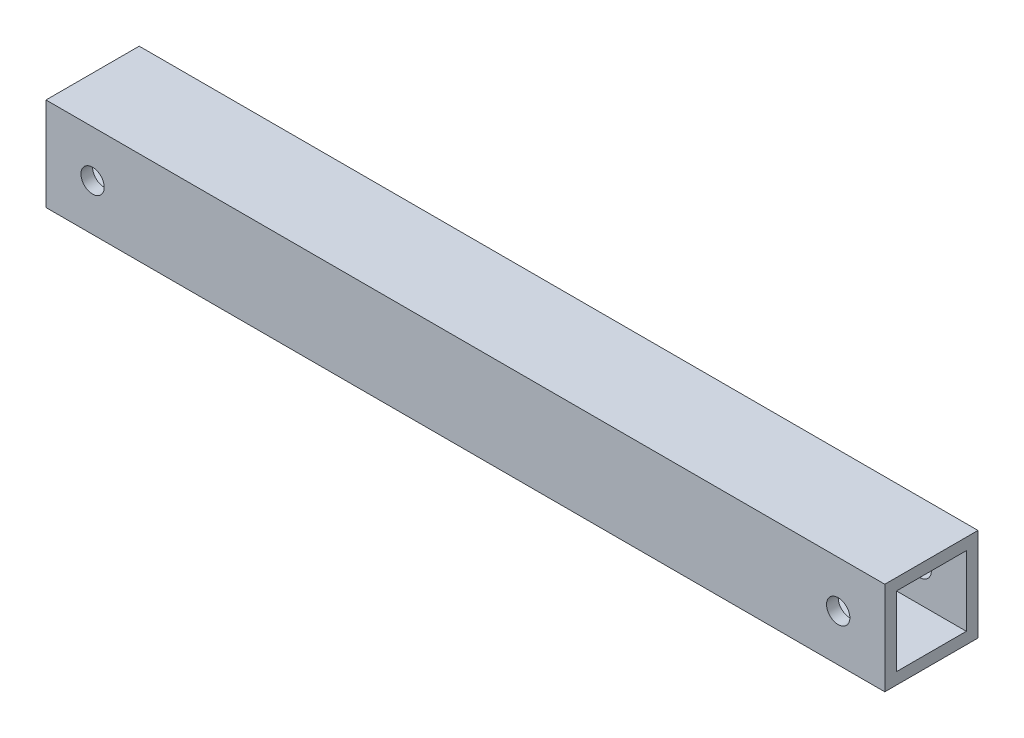
from build123d import *

# Parameters (mm, degrees)
SKETCH1_W           = 228.6
SKETCH1_H           = 25.4
BOSS_EXTRUDE1_DEPTH = 25.4
SKETCH2_W           = 9.525
SKETCH2_H           = 19.040717284
CUT_EXTRUDE1_DEPTH  = 508
SKETCH4_R           = 3.175
CUT_EXTRUDE3_DEPTH  = 508


with BuildPart() as part:
    # Sketch1 → Boss-Extrude1 (new body)
    with BuildSketch(Plane.XY):
        Rectangle(SKETCH1_W, SKETCH1_H)
    extrude(amount=BOSS_EXTRUDE1_DEPTH)

    # Sketch2 → Cut-Extrude1 (cut)
    with BuildSketch(Plane(origin=(114.3, 0, 0), x_dir=(0, 0, -1), z_dir=(1, 0, 0))):
        with Locations((-17.4625, 0)):
            Rectangle(SKETCH2_W, SKETCH2_H)
        with Locations((-7.9375, 0)):
            Rectangle(SKETCH2_W, SKETCH2_H)
    extrude(amount=-CUT_EXTRUDE1_DEPTH, mode=Mode.SUBTRACT)

    # Sketch4 → Cut-Extrude3 (cut)
    with BuildSketch(Plane.XY.offset(25.4)):
        with Locations((-101.6, 0)):
            Circle(SKETCH4_R)
        with Locations((101.6, 0)):
            Circle(SKETCH4_R)
    extrude(amount=-CUT_EXTRUDE3_DEPTH, mode=Mode.SUBTRACT)


solid = part.part
